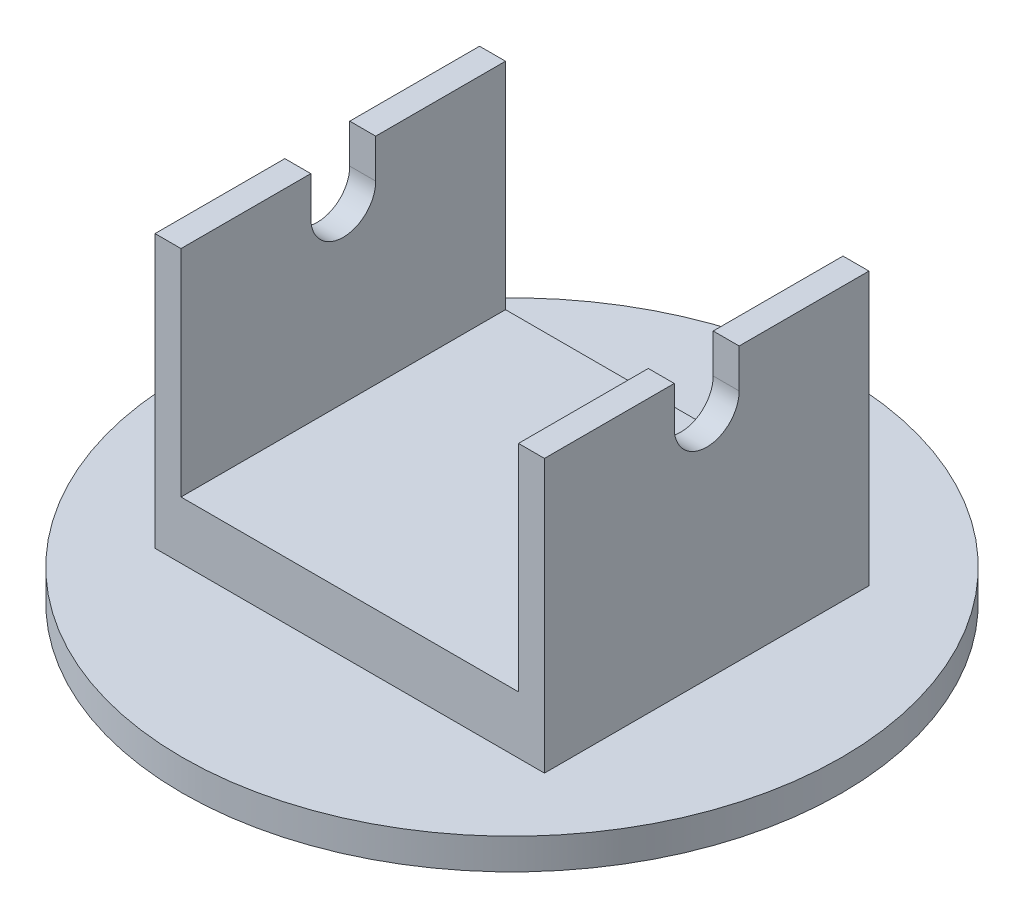
from build123d import *

# Parameters (mm, degrees)
SKETCH2_R               = 50.8
BOSS_EXTRUDE1_DEPTH     = 4.7625
BOSS_EXTRUDE2_DEPTH     = 30
SKETCH7_W               = 60
SKETCH7_H               = 50
BOSS_EXTRUDE3_DEPTH     = 46.7625
CUT_EXTRUDE2_DEPTH      = 81.8
SKETCH5_W               = 52
SKETCH5_H               = 33.1537
CUT_EXTRUDE1_DEPTH      = 51.8
CUT_EXTRUDE1_DEPTH_BACK = 51.8


with BuildPart() as part:
    # Sketch2 → Boss-Extrude1 (new body)
    with BuildSketch(Plane(origin=(0, 0, 0), x_dir=(-1, 0, 0), z_dir=(0, 1, 0))):
        Circle(SKETCH2_R)
    extrude(amount=BOSS_EXTRUDE1_DEPTH)

    # Sketch4 → Boss-Extrude2 (add, symmetric)
    with BuildSketch(Plane(origin=(0, 0, 0), x_dir=(0, 0, -1), z_dir=(1, 0, 0))):
        Polygon((-25, 4.7625), (25, 4.7625), (16, 46.7625), (-16, 46.7625), align=None)
    extrude(amount=BOSS_EXTRUDE2_DEPTH, both=True)

    # Sketch7 → Boss-Extrude3 (add)
    with BuildSketch(Plane(origin=(0, 0, 0), x_dir=(-1, 0, 0), z_dir=(0, 1, 0))):
        Rectangle(SKETCH7_W, SKETCH7_H)
    extrude(amount=BOSS_EXTRUDE3_DEPTH)

    # Sketch6 → Cut-Extrude2 (cut, through all)
    with BuildSketch(Plane(origin=(30, 0, 0), x_dir=(0, 0, -1), z_dir=(1, 0, 0))):
        with BuildLine():
            Line((5, 40.7625), (5, 46.7625))
            Line((5, 46.7625), (-5, 46.7625))
            Line((-5, 46.7625), (-5, 40.7625))
            ThreePointArc((-5, 40.7625), (0, 35.7625), (5, 40.7625))
        make_face()
    extrude(amount=-CUT_EXTRUDE2_DEPTH, mode=Mode.SUBTRACT)

    # Sketch5 → Cut-Extrude1 (cut, two sides)
    with BuildSketch(Plane.XY) as cut_extrude1_sk:
        with Locations((0, 30.18565)):
            Rectangle(SKETCH5_W, SKETCH5_H)
    extrude(amount=CUT_EXTRUDE1_DEPTH, mode=Mode.SUBTRACT)
    extrude(cut_extrude1_sk.sketch, amount=-CUT_EXTRUDE1_DEPTH_BACK, mode=Mode.SUBTRACT)


solid = part.part
